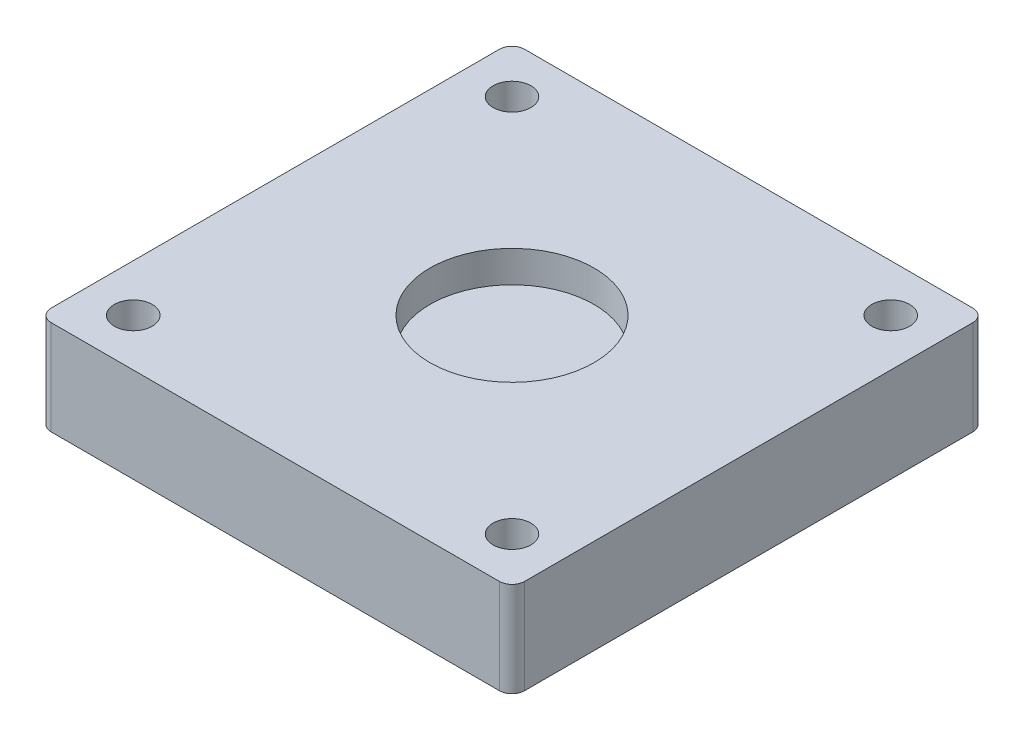
from build123d import *

# Parameters (mm, degrees)
SKETCH1_W           = 75
SKETCH1_H           = 15
BOSS_EXTRUDE1_DEPTH = 37.5
SKETCH2_R           = 13
SKETCH2_R_2         = 3
CUT_EXTRUDE1_DEPTH  = 5
SKETCH3_R           = 2
CUT_EXTRUDE2_DEPTH  = 11
FILLET1_R           = 2


with BuildPart() as part:
    # Sketch1 → Boss-Extrude1 (new body, symmetric)
    with BuildSketch(Plane.XY):
        Rectangle(SKETCH1_W, SKETCH1_H)
    extrude(amount=BOSS_EXTRUDE1_DEPTH, both=True)

    # Sketch2 → Cut-Extrude1 (cut)
    with BuildSketch(Plane(origin=(0, 7.5, 0), x_dir=(1, 0, 0), z_dir=(0, 1, 0))):
        Circle(SKETCH2_R)
        with Locations((-30, 30)):
            Circle(SKETCH2_R_2)
        with Locations((-30, -30)):
            Circle(SKETCH2_R_2)
        with Locations((30, -30)):
            Circle(SKETCH2_R_2)
        with Locations((30, 30)):
            Circle(SKETCH2_R_2)
    extrude(amount=-CUT_EXTRUDE1_DEPTH, mode=Mode.SUBTRACT)

    # Sketch3 → Cut-Extrude2 (cut, through all)
    with BuildSketch(Plane(origin=(0, 2.5, 0), x_dir=(1, 0, 0), z_dir=(0, 1, 0))):
        with Locations((-30, 30)):
            Circle(SKETCH3_R)
        with Locations((30, 30)):
            Circle(SKETCH3_R)
        with Locations((30, -30)):
            Circle(SKETCH3_R)
        with Locations((-30, -30)):
            Circle(SKETCH3_R)
    extrude(amount=-CUT_EXTRUDE2_DEPTH, mode=Mode.SUBTRACT)

    # Fillet1
    fillet1_edges = [part.edges().sort_by_distance(p)[0] for p in [
        (-37.5, 0, 37.5),
        (37.5, 0, 37.5),
        (-37.5, 0, -37.5),
        (37.5, 0, -37.5),
    ]]
    fillet(fillet1_edges, radius=FILLET1_R)


solid = part.part
